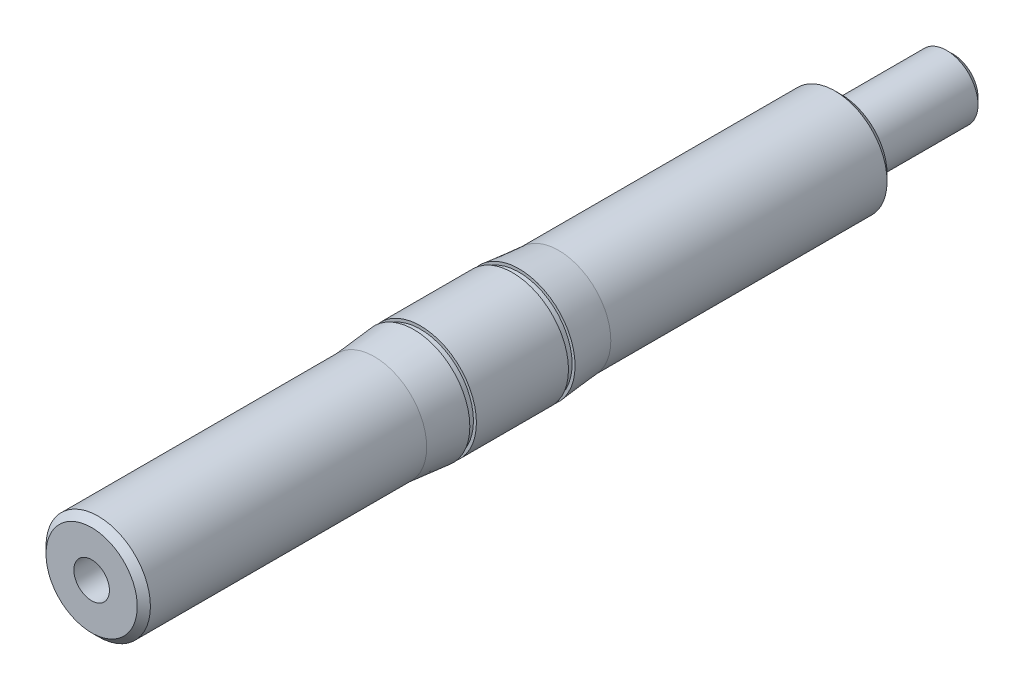
from build123d import *

# Parameters (mm, degrees)
CHAMFER1_SIZE               = 1
SKETCH3_R                   = 4.7625
BOSS_EXTRUDE1_DEPTH         = 17
CHAMFER2_SIZE               = 1
F_1_4_28_TAPPED_HOLE1_D     = 5.4102
F_1_4_28_TAPPED_HOLE1_DEPTH = 15.42
F_1_4_28_TAPPED_HOLE1_TIP   = 1.625388061


with BuildPart() as part:
    # Sketch1 → Revolve1 (revolve)
    with BuildSketch(Plane(origin=(0, 0, 0), x_dir=(0, 0, -1), z_dir=(1, 0, 0))):
        Polygon((-8, 8.5), (-14, 7.9375), (-35, 7.9375), (-57, 7.9375), (-57, 0), (57, 0), (57, 7.9375), (35, 7.9375), (14, 7.9375), (8, 8.5), (8, 8.05), (7, 8.05), (7, 8.5), (-7, 8.5), (-7, 8.05), (-8, 8.05), align=None)
    revolve(axis=Axis((0, 0, 83.804844788), (0, 0, -1)))

    # Chamfer1
    chamfer1_edges = [part.edges().sort_by_distance(p)[0] for p in [
        (0, -7.9375, 57),
        (0, -7.9375, -57),
    ]]
    chamfer(chamfer1_edges, length=CHAMFER1_SIZE)

    # Sketch3 → Boss-Extrude1 (add)
    with BuildSketch(Plane.XY.offset(-57)):
        Circle(SKETCH3_R)
    extrude(amount=-BOSS_EXTRUDE1_DEPTH)

    # Chamfer2
    chamfer2_edges = [part.edges().sort_by_distance(p)[0] for p in [
        (-4.7625, 0, -74),
    ]]
    chamfer(chamfer2_edges, length=CHAMFER2_SIZE)

    # 1_4-28 Tapped Hole1
    with Locations(Plane.XY.offset(57)):
        with Locations((0, 0)):
            Hole(F_1_4_28_TAPPED_HOLE1_D / 2, depth=F_1_4_28_TAPPED_HOLE1_DEPTH)
            with Locations((0, 0, -(F_1_4_28_TAPPED_HOLE1_DEPTH + F_1_4_28_TAPPED_HOLE1_TIP / 2))):  # 118° drill point
                Cone(0, F_1_4_28_TAPPED_HOLE1_D / 2, F_1_4_28_TAPPED_HOLE1_TIP, mode=Mode.SUBTRACT)


solid = part.part
